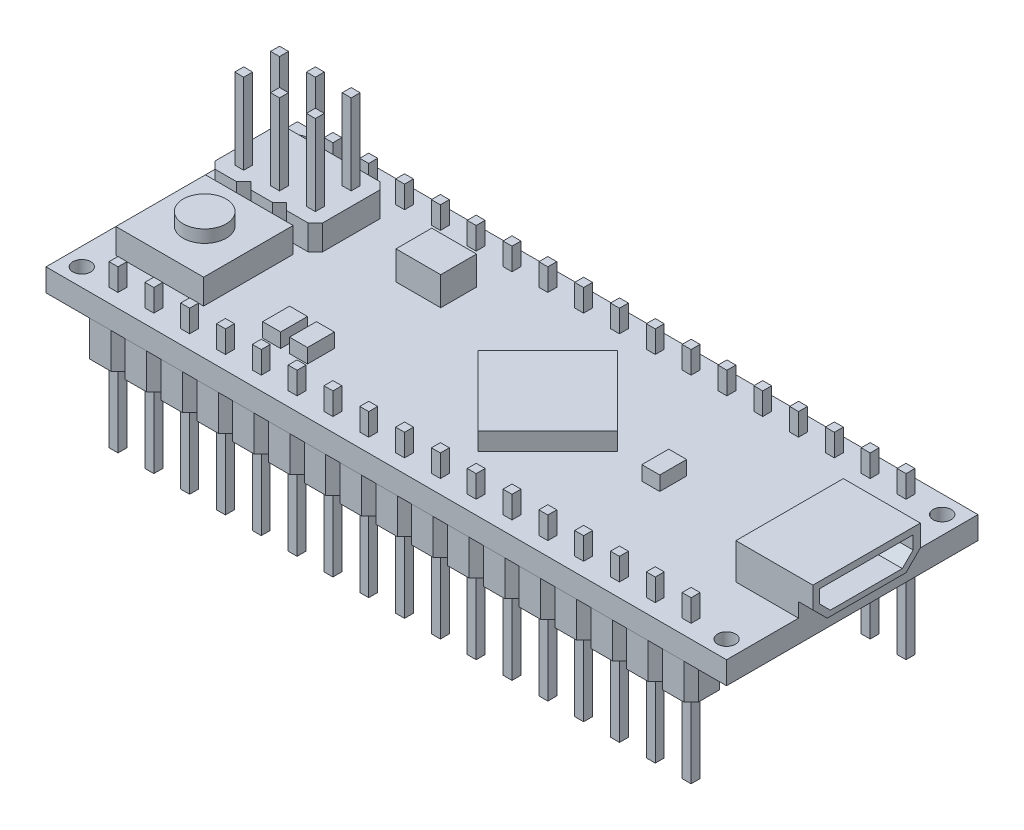
from build123d import *

# Parameters (mm, degrees)
SKETCH1_W            = 48.26
SKETCH1_H            = 17.8308
BOSS_EXTRUDE1_DEPTH  = 1.6002
BOSS_EXTRUDE2_DEPTH  = 1.27
SKETCH3_W            = 6.223
SKETCH3_H            = 6.35
BOSS_EXTRUDE3_DEPTH  = 1.778
SKETCH4_R            = 1.524
BOSS_EXTRUDE4_DEPTH  = 0.889
SKETCH5_W            = 5.461
SKETCH5_H            = 7.62
BOSS_EXTRUDE5_DEPTH  = 2.54
CUT_EXTRUDE1_DEPTH   = 4.318
BOSS_EXTRUDE6_DEPTH  = 1.778
SKETCH8_W            = 0.635
SKETCH8_H            = 0.635
BOSS_EXTRUDE7_DEPTH  = 5.715
LPATTERN1_COUNT      = 3
LPATTERN1_PITCH      = 2.54
SKETCH9_R            = 0.635
CUT_EXTRUDE2_DEPTH   = 2.6002
BOSS_EXTRUDE8_DEPTH  = 2.54
SKETCH11_W           = 0.635
SKETCH11_H           = 0.635
BOSS_EXTRUDE9_DEPTH  = 5.715
LPATTERN2_COUNT      = 17
LPATTERN2_PITCH      = 2.54
LPATTERN2_COUNT_DIR2 = 2
LPATTERN2_PITCH_DIR2 = 15.24
SKETCH12_W           = 1.27
SKETCH12_H           = 1.905
BOSS_EXTRUDE10_DEPTH = 1.016
SKETCH13_W           = 1.27
SKETCH13_H           = 1.905
BOSS_EXTRUDE11_DEPTH = 1.016
SKETCH14_W           = 3.175
SKETCH14_H           = 2.54
BOSS_EXTRUDE12_DEPTH = 2.032
CHAMFER1_SIZE        = 1.016


with BuildPart() as part:
    # Sketch1 → Boss-Extrude1 (new body)
    with BuildSketch(Plane(origin=(0, 0, 0), x_dir=(1, 0, 0), z_dir=(0, 1, 0))):
        Rectangle(SKETCH1_W, SKETCH1_H)
    extrude(amount=BOSS_EXTRUDE1_DEPTH)

    # Sketch2 → Boss-Extrude2 (add)
    with BuildSketch(Plane(origin=(0, 1.6002, 0), x_dir=(1, 0, 0), z_dir=(0, 1, 0))):
        Polygon((-2.399140867, 0), (2.54, -4.939140867), (7.479140867, 0), (2.54, 4.939140867), align=None)
    extrude(amount=BOSS_EXTRUDE2_DEPTH)

    # Sketch3 → Boss-Extrude3 (add)
    with BuildSketch(Plane(origin=(0, 1.6002, 0), x_dir=(1, 0, 0), z_dir=(0, 1, 0))):
        with Locations((-19.2405, -2.5654)):
            Rectangle(SKETCH3_W, SKETCH3_H)
    extrude(amount=BOSS_EXTRUDE3_DEPTH)

    # Sketch4 → Boss-Extrude4 (add)
    with BuildSketch(Plane(origin=(0, 3.3782, 0), x_dir=(1, 0, 0), z_dir=(0, 1, 0))):
        with Locations((-19.2405, -2.5527)):
            Circle(SKETCH4_R)
    extrude(amount=BOSS_EXTRUDE4_DEPTH)

    # Sketch5 → Boss-Extrude5 (add)
    with BuildSketch(Plane(origin=(0, 1.6002, 0), x_dir=(1, 0, 0), z_dir=(0, 1, 0))):
        with Locations((22.4155, 0)):
            Rectangle(SKETCH5_W, SKETCH5_H)
    extrude(amount=BOSS_EXTRUDE5_DEPTH)

    # Sketch6 → Cut-Extrude1 (cut)
    with BuildSketch(Plane(origin=(25.146, 0, 0), x_dir=(0, 0, -1), z_dir=(1, 0, 0))):
        Polygon((-3.332819861, 2.744964074), (-2.570819861, 1.982964074), (2.53316088, 1.982964074), (3.29516088, 2.744964074), (3.29516088, 3.677618241), (-3.332819861, 3.677618241), align=None)
    extrude(amount=-CUT_EXTRUDE1_DEPTH, mode=Mode.SUBTRACT)

    # Sketch7 → Boss-Extrude6 (add)
    with BuildSketch(Plane(origin=(0, 1.6002, 0), x_dir=(1, 0, 0), z_dir=(0, 1, 0))):
        Polygon((-22.352, 6.3754), (-20.828, 6.3754), (-20.32, 5.8674), (-20.32, 1.8034), (-20.828, 1.2954), (-22.352, 1.2954), (-22.86, 1.8034), (-22.86, 5.8674), align=None)
    boss_extrude6 = extrude(amount=BOSS_EXTRUDE6_DEPTH)

    # Sketch8 → Boss-Extrude7 (add)
    with BuildSketch(Plane(origin=(0, 3.3782, 0), x_dir=(1, 0, 0), z_dir=(0, 1, 0))):
        with Locations((-21.59, 5.1054)):
            Rectangle(SKETCH8_W, SKETCH8_H)
        with Locations((-21.59, 2.5654)):
            Rectangle(SKETCH8_W, SKETCH8_H)
    boss_extrude7 = extrude(amount=BOSS_EXTRUDE7_DEPTH)

    # LPattern1: Boss-Extrude6, Boss-Extrude7 ×3
    with Locations(*[(i * LPATTERN1_PITCH, 0, 0) for i in range(1, LPATTERN1_COUNT)]):
        add(boss_extrude6)
        add(boss_extrude7)

    # Sketch9 → Cut-Extrude2 (cut, through all)
    with BuildSketch(Plane(origin=(0, 1.6002, 0), x_dir=(1, 0, 0), z_dir=(0, 1, 0))):
        with Locations((-22.86, 7.6454)):
            Circle(SKETCH9_R)
        with Locations((-22.86, -7.6454)):
            Circle(SKETCH9_R)
        with Locations((22.86, -7.6454)):
            Circle(SKETCH9_R)
        with Locations((22.86, 7.6454)):
            Circle(SKETCH9_R)
    extrude(amount=-CUT_EXTRUDE2_DEPTH, mode=Mode.SUBTRACT)

    # Sketch10 → Boss-Extrude8 (add)
    with BuildSketch(Plane.XZ):
        Polygon((-21.59, 6.858), (-21.082, 6.35), (-19.558, 6.35), (-19.05, 6.858), (-19.05, 8.382), (-19.558, 8.89), (-21.082, 8.89), (-21.59, 8.382), align=None)
    boss_extrude8 = extrude(amount=BOSS_EXTRUDE8_DEPTH)

    # Sketch11 → Boss-Extrude9 (add, symmetric)
    with BuildSketch(Plane.XZ.offset(2.54)):
        with Locations((-20.32, 7.62)):
            Rectangle(SKETCH11_W, SKETCH11_H)
    boss_extrude9 = extrude(amount=BOSS_EXTRUDE9_DEPTH, both=True)

    # LPattern2: Boss-Extrude8, Boss-Extrude9 17 × 2
    with Locations(*[(i * LPATTERN2_PITCH, 0, -j * LPATTERN2_PITCH_DIR2) for i in range(LPATTERN2_COUNT) for j in range(LPATTERN2_COUNT_DIR2) if (i, j) != (0, 0)]):
        add(boss_extrude8)
        add(boss_extrude9)

    # Sketch12 → Boss-Extrude10 (add)
    with BuildSketch(Plane(origin=(0, 1.6002, 0), x_dir=(1, 0, 0), z_dir=(0, 1, 0))):
        with Locations((-11.43, -4.6609)):
            Rectangle(SKETCH12_W, SKETCH12_H)
        with Locations((-9.525, -4.6609)):
            Rectangle(SKETCH12_W, SKETCH12_H)
    extrude(amount=BOSS_EXTRUDE10_DEPTH)

    # Sketch13 → Boss-Extrude11 (add)
    with BuildSketch(Plane(origin=(0, 1.6002, 0), x_dir=(1, 0, 0), z_dir=(0, 1, 0))):
        with Locations((10.795, 0)):
            Rectangle(SKETCH13_W, SKETCH13_H)
    extrude(amount=BOSS_EXTRUDE11_DEPTH)

    # Sketch14 → Boss-Extrude12 (add)
    with BuildSketch(Plane(origin=(0, 1.6002, 0), x_dir=(1, 0, 0), z_dir=(0, 1, 0))):
        with Locations((-9.2075, 3.8354)):
            Rectangle(SKETCH14_W, SKETCH14_H)
    extrude(amount=BOSS_EXTRUDE12_DEPTH)

    # Chamfer1
    chamfer1_edges = [part.edges().sort_by_distance(p)[0] for p in [
        (24.638, 1.6002, 3.81),
        (24.638, 1.6002, -3.81),
    ]]
    chamfer(chamfer1_edges, length=CHAMFER1_SIZE)


solid = part.part
